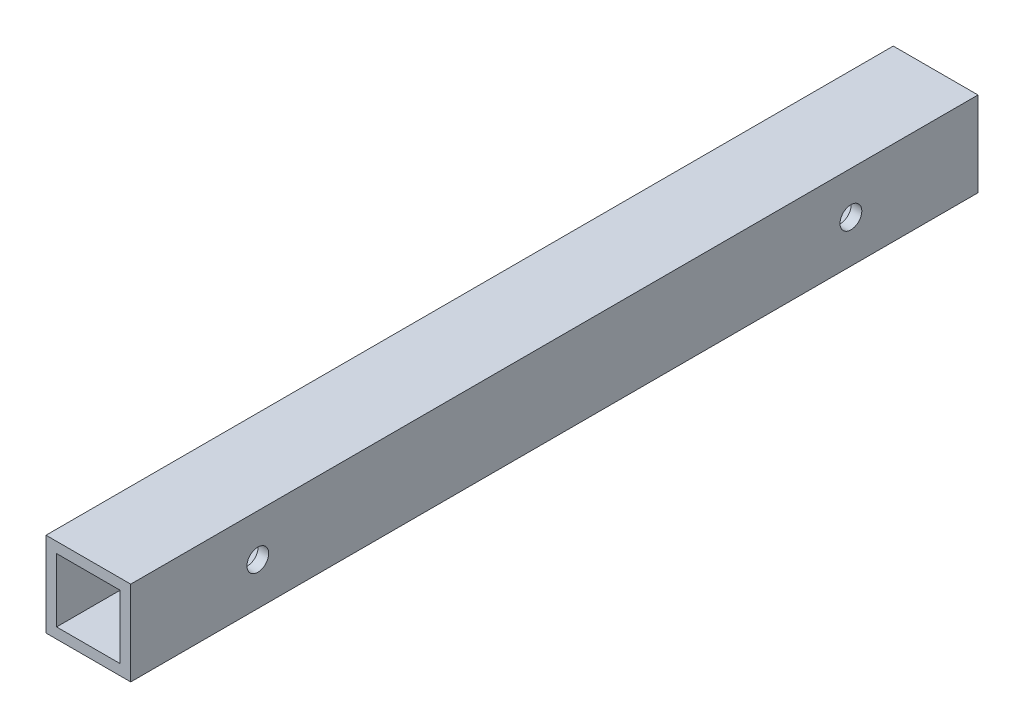
from build123d import *

# Parameters (mm, degrees)
SKETCH1_W                = 25.4
SKETCH1_H                = 25.4
SKETCH1_W_2              = 19.05
SKETCH1_H_2              = 19.05
BOSS_EXTRUDE1_DEPTH      = 254
F_0_257_DIAMETER_HOLE1_D = 6.5278


with BuildPart() as part:
    # Sketch1 → Boss-Extrude1 (new body)
    with BuildSketch(Plane.XY):
        Rectangle(SKETCH1_W, SKETCH1_H)
        Rectangle(SKETCH1_W_2, SKETCH1_H_2, mode=Mode.SUBTRACT)
    extrude(amount=BOSS_EXTRUDE1_DEPTH)

    # F (0.257) Diameter Hole1 (through all)
    with Locations(Plane(origin=(12.7, 0, 0), x_dir=(0, 0, -1), z_dir=(1, 0, 0))):
        with Locations((-215.9, 0), (-38.1, 0)):
            Hole(F_0_257_DIAMETER_HOLE1_D / 2)


solid = part.part
